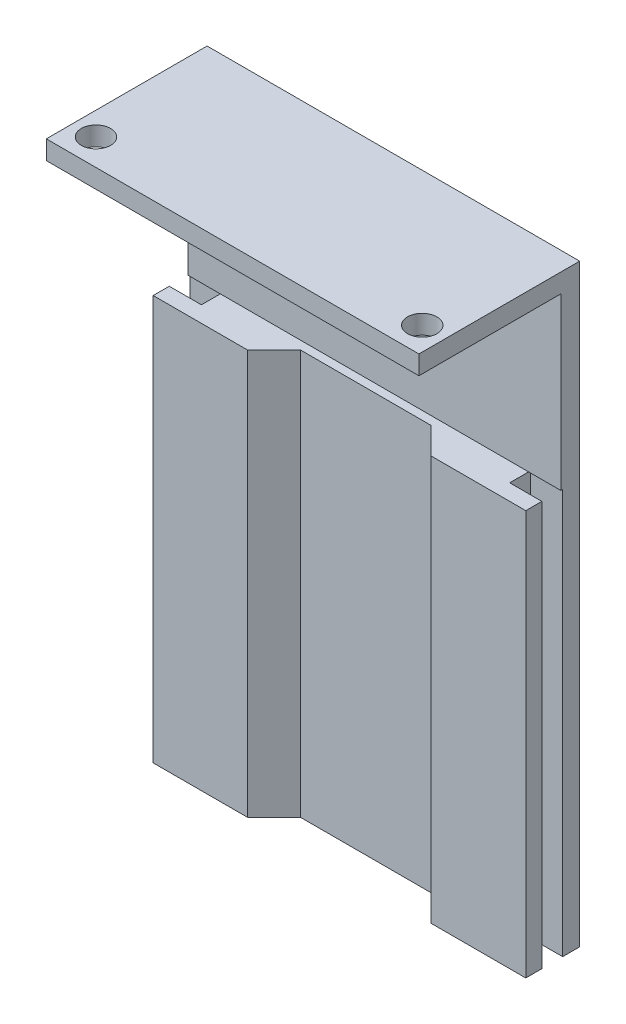
from build123d import *

# Parameters (mm, degrees)
RESSALTO_EXTRUS_O1_DEPTH = 63
ESBO_O2_W                = 3.8
ESBO_O2_H                = 20
CORTE_EXTRUS_O1_DEPTH    = 41
ESBO_O3_W                = 40
ESBO_O3_H                = 2
RESSALTO_EXTRUS_O2_DEPTH = 15
ESBO_O4_R                = 1.55
CORTE_EXTRUS_O2_DEPTH    = 3
ESBO_O5_W                = 0.3
ESBO_O5_H                = 17
CORTE_EXTRUS_O3_DEPTH    = 64
ESBO_O6_W                = 3.6
ESBO_O6_H                = 2.2
CORTE_EXTRUS_O4_DEPTH    = 43
ESBO_O7_W                = 39.4
ESBO_O7_H                = 0.1
CORTE_EXTRUS_O5_DEPTH    = 46
CORTE_EXTRUS_O6_DEPTH    = 43
ESBO_O9_W                = 39.4
ESBO_O9_H                = 0.2
CORTE_EXTRUS_O7_DEPTH    = 10


with BuildPart() as part:
    # Esboço1 → Ressalto-extrusão1 (new body)
    with BuildSketch(Plane(origin=(0, 0, 0), x_dir=(1, 0, 0), z_dir=(0, 1, 0))):
        Polygon((-20, 2.9), (20, 2.9), (20, 0.9), (16.5, 0.9), (16.5, -0.9), (20, -0.9), (20, -2.9), (-20, -2.9), (-20, -0.9), (-16.5, -0.9), (-16.5, 0.9), (-20, 0.9), align=None)
    extrude(amount=RESSALTO_EXTRUS_O1_DEPTH)

    # Esboço2 → Corte-extrusão1 (cut, through all)
    with BuildSketch(Plane(origin=(20, 0, 0), x_dir=(0, 0, -1), z_dir=(1, 0, 0))):
        with Locations((-1, 53)):
            Rectangle(ESBO_O2_W, ESBO_O2_H)
    extrude(amount=-CORTE_EXTRUS_O1_DEPTH, mode=Mode.SUBTRACT)

    # Esboço3 → Ressalto-extrusão2 (add)
    with BuildSketch(Plane.XY.offset(-0.9)):
        with Locations((0, 62)):
            Rectangle(ESBO_O3_W, ESBO_O3_H)
    extrude(amount=RESSALTO_EXTRUS_O2_DEPTH)

    # Esboço4 → Corte-extrusão2 (cut)
    with BuildSketch(Plane(origin=(0, 63, 0), x_dir=(1, 0, 0), z_dir=(0, 1, 0))):
        with Locations((-17.25, -11.3)):
            Circle(ESBO_O4_R)
        with Locations((17.25, -11.3)):
            Circle(ESBO_O4_R)
    extrude(amount=-CORTE_EXTRUS_O2_DEPTH, mode=Mode.SUBTRACT)

    # Esboço5 → Corte-extrusão3 (cut, through all)
    with BuildSketch(Plane.XZ):
        with Locations((-19.85, 5.6)):
            Rectangle(ESBO_O5_W, ESBO_O5_H)
        with Locations((19.85, 5.6)):
            Rectangle(ESBO_O5_W, ESBO_O5_H)
    extrude(amount=-CORTE_EXTRUS_O3_DEPTH, mode=Mode.SUBTRACT)

    # Esboço6 → Corte-extrusão4 (cut)
    with BuildSketch(Plane.XZ):
        with Locations((18.1, 0)):
            Rectangle(ESBO_O6_W, ESBO_O6_H)
        with Locations((-18.1, 0)):
            Rectangle(ESBO_O6_W, ESBO_O6_H)
    extrude(amount=-CORTE_EXTRUS_O4_DEPTH, mode=Mode.SUBTRACT)

    # Esboço7 → Corte-extrusão5 (cut)
    with BuildSketch(Plane.XZ):
        with Locations((0, 2.85)):
            Rectangle(ESBO_O7_W, ESBO_O7_H)
    extrude(amount=-CORTE_EXTRUS_O5_DEPTH, mode=Mode.SUBTRACT)

    # Esboço8 → Corte-extrusão6 (cut)
    with BuildSketch(Plane.XZ):
        Polygon((9.7, 2.8), (6.9, 0), (-6.135691889, 0), (-6.9, 0), (-9.7, 2.8), align=None)
    extrude(amount=-CORTE_EXTRUS_O6_DEPTH, mode=Mode.SUBTRACT)

    # Esboço9 → Corte-extrusão7 (cut)
    with BuildSketch(Plane.XY.offset(2.8)):
        with Locations((0, 0.1)):
            Rectangle(ESBO_O9_W, ESBO_O9_H)
    extrude(amount=-CORTE_EXTRUS_O7_DEPTH, mode=Mode.SUBTRACT)


solid = part.part
